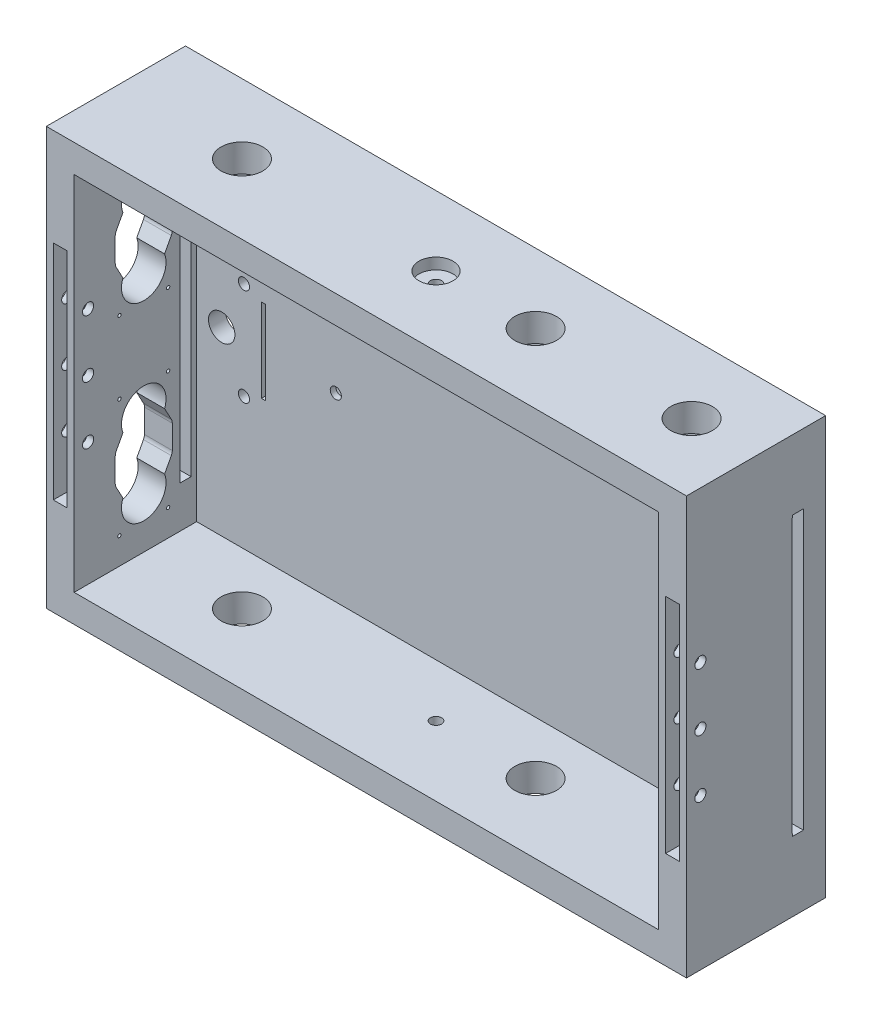
from build123d import *

# Parameters (mm, degrees)
SKETCH1_W           = 230
SKETCH1_H           = 50
BOSS_EXTRUDE1_DEPTH = 150
SKETCH2_W           = 210
SKETCH2_H           = 130
CUT_EXTRUDE1_DEPTH  = 44
SKETCH3_R           = 6.125
CUT_EXTRUDE2_DEPTH  = 4
SKETCH4_R           = 6.125
CUT_EXTRUDE4_DEPTH  = 4
SKETCH5_R           = 6.125
CUT_EXTRUDE5_DEPTH  = 4
SKETCH7_R           = 2
CUT_EXTRUDE7_DEPTH  = 47
SKETCH8_R           = 2
CUT_EXTRUDE8_DEPTH  = 147
CUT_EXTRUDE9_REACH  = 52
SKETCH10_R          = 2
SKETCH10_R_2        = 4.75
SKETCH10_W          = 1.5
SKETCH10_H          = 30
SKETCH11_R          = 7.5
CUT_EXTRUDE10_DEPTH = 151
CUT_EXTRUDE12_REACH = 232
SKETCH14_R          = 0.6
SKETCH15_W          = 5
SKETCH15_H          = 80
CUT_EXTRUDE13_DEPTH = 10
SKETCH16_R          = 2
CUT_EXTRUDE14_DEPTH = 231
CUT_EXTRUDE15_DEPTH = 231


with BuildPart() as part:
    # Sketch1 → Boss-Extrude1 (new body)
    with BuildSketch(Plane(origin=(0, 0, 0), x_dir=(1, 0, 0), z_dir=(0, 1, 0))):
        with Locations((115, 25)):
            Rectangle(SKETCH1_W, SKETCH1_H)
    extrude(amount=BOSS_EXTRUDE1_DEPTH)

    # Sketch2 → Cut-Extrude1 (cut)
    with BuildSketch(Plane.XY):
        with Locations((115, 75)):
            Rectangle(SKETCH2_W, SKETCH2_H)
    extrude(amount=-CUT_EXTRUDE1_DEPTH, mode=Mode.SUBTRACT)

    # Sketch3 → Cut-Extrude2 (cut)
    with BuildSketch(Plane(origin=(0, 150, 0), x_dir=(1, 0, 0), z_dir=(0, 1, 0))):
        with Locations((115, 25)):
            Circle(SKETCH3_R)
    extrude(amount=-CUT_EXTRUDE2_DEPTH, mode=Mode.SUBTRACT)

    # Sketch4 → Cut-Extrude4 (cut)
    with BuildSketch(Plane(origin=(0, 0, 0), x_dir=(1, 0, 0), z_dir=(0, 1, 0))):
        with Locations((115, 25)):
            Circle(SKETCH4_R)
    extrude(amount=CUT_EXTRUDE4_DEPTH, mode=Mode.SUBTRACT)

    # Sketch5 → Cut-Extrude5 (cut)
    with BuildSketch(Plane(origin=(0, 0, -50), x_dir=(-1, 0, 0), z_dir=(0, 0, -1))):
        with Locations((-60, 75)):
            Circle(SKETCH5_R)
    extrude(amount=-CUT_EXTRUDE5_DEPTH, mode=Mode.SUBTRACT)

    # Sketch7 → Cut-Extrude7 (cut, through all)
    with BuildSketch(Plane(origin=(0, 0, -46), x_dir=(-1, 0, 0), z_dir=(0, 0, -1))):
        with Locations((-60, 75)):
            Circle(SKETCH7_R)
    extrude(amount=-CUT_EXTRUDE7_DEPTH, mode=Mode.SUBTRACT)

    # Sketch8 → Cut-Extrude8 (cut, through all)
    with BuildSketch(Plane(origin=(0, 146, 0), x_dir=(1, 0, 0), z_dir=(0, 1, 0))):
        with Locations((115, 25)):
            Circle(SKETCH8_R)
    extrude(amount=-CUT_EXTRUDE8_DEPTH, mode=Mode.SUBTRACT)

    # Sketch10 → Cut-Extrude9 (cut, up to next)
    with BuildSketch(Plane(origin=(0, 0, -50), x_dir=(-1, 0, 0), z_dir=(0, 0, -1)), mode=Mode.PRIVATE) as cut_extrude9_sk1:
        with Locations((-27, 92.5)):
            Circle(SKETCH10_R)
    cut_extrude9_tool1 = extrude(cut_extrude9_sk1.sketch, amount=-CUT_EXTRUDE9_REACH, mode=Mode.PRIVATE) & part.part
    add(cut_extrude9_tool1.solids().sort_by_distance((27, 92.5, -50))[0], mode=Mode.SUBTRACT)
    # Sketch10 → Cut-Extrude9 (cut, up to next)
    with BuildSketch(Plane(origin=(0, 0, -50), x_dir=(-1, 0, 0), z_dir=(0, 0, -1)), mode=Mode.PRIVATE) as cut_extrude9_sk2:
        with Locations((-27, 57.5)):
            Circle(SKETCH10_R)
    cut_extrude9_tool2 = extrude(cut_extrude9_sk2.sketch, amount=-CUT_EXTRUDE9_REACH, mode=Mode.PRIVATE) & part.part
    add(cut_extrude9_tool2.solids().sort_by_distance((27, 57.5, -50))[0], mode=Mode.SUBTRACT)
    # Sketch10 → Cut-Extrude9 (cut, up to next)
    with BuildSketch(Plane(origin=(0, 0, -50), x_dir=(-1, 0, 0), z_dir=(0, 0, -1)), mode=Mode.PRIVATE) as cut_extrude9_sk3:
        with Locations((-19, 75)):
            Circle(SKETCH10_R_2)
    cut_extrude9_tool3 = extrude(cut_extrude9_sk3.sketch, amount=-CUT_EXTRUDE9_REACH, mode=Mode.PRIVATE) & part.part
    add(cut_extrude9_tool3.solids().sort_by_distance((19, 75, -50))[0], mode=Mode.SUBTRACT)
    # Sketch10 → Cut-Extrude9 (cut, up to next)
    with BuildSketch(Plane(origin=(0, 0, -50), x_dir=(-1, 0, 0), z_dir=(0, 0, -1)), mode=Mode.PRIVATE) as cut_extrude9_sk4:
        with Locations((-34.018423534, 75)):
            Rectangle(SKETCH10_W, SKETCH10_H)
    cut_extrude9_tool4 = extrude(cut_extrude9_sk4.sketch, amount=-CUT_EXTRUDE9_REACH, mode=Mode.PRIVATE) & part.part
    add(cut_extrude9_tool4.solids().sort_by_distance((34.018424, 75, -50))[0], mode=Mode.SUBTRACT)

    # Sketch11 → Cut-Extrude10 (cut, through all)
    with BuildSketch(Plane(origin=(0, 150, 0), x_dir=(1, 0, 0), z_dir=(0, 1, 0))):
        with Locations((45.280155496, 25)):
            Circle(SKETCH11_R)
        with Locations((150.781597071, 25)):
            Circle(SKETCH11_R)
        with Locations((206.820659907, 25)):
            Circle(SKETCH11_R)
    extrude(amount=-CUT_EXTRUDE10_DEPTH, mode=Mode.SUBTRACT)

    # Sketch14 → Cut-Extrude12 (cut, up to next)
    with BuildSketch(Plane.ZY, mode=Mode.PRIVATE) as cut_extrude12_sk1:
        with Locations((-33.75, 62)):
            Circle(SKETCH14_R)
    cut_extrude12_tool1 = extrude(cut_extrude12_sk1.sketch, amount=-CUT_EXTRUDE12_REACH, mode=Mode.PRIVATE) & part.part
    add(cut_extrude12_tool1.solids().sort_by_distance((0, 62, -33.75))[0], mode=Mode.SUBTRACT)
    # Sketch14 → Cut-Extrude12 (cut, up to next)
    with BuildSketch(Plane.ZY, mode=Mode.PRIVATE) as cut_extrude12_sk2:
        with Locations((-16.25, 19.5)):
            Circle(SKETCH14_R)
    cut_extrude12_tool2 = extrude(cut_extrude12_sk2.sketch, amount=-CUT_EXTRUDE12_REACH, mode=Mode.PRIVATE) & part.part
    add(cut_extrude12_tool2.solids().sort_by_distance((0, 19.5, -16.25))[0], mode=Mode.SUBTRACT)
    # Sketch14 → Cut-Extrude12 (cut, up to next)
    with BuildSketch(Plane.ZY, mode=Mode.PRIVATE) as cut_extrude12_sk3:
        with Locations((-16.25, 62)):
            Circle(SKETCH14_R)
    cut_extrude12_tool3 = extrude(cut_extrude12_sk3.sketch, amount=-CUT_EXTRUDE12_REACH, mode=Mode.PRIVATE) & part.part
    add(cut_extrude12_tool3.solids().sort_by_distance((0, 62, -16.25))[0], mode=Mode.SUBTRACT)
    # Sketch14 → Cut-Extrude12 (cut, up to next)
    with BuildSketch(Plane.ZY, mode=Mode.PRIVATE) as cut_extrude12_sk4:
        with Locations((-33.75, 19.5)):
            Circle(SKETCH14_R)
    cut_extrude12_tool4 = extrude(cut_extrude12_sk4.sketch, amount=-CUT_EXTRUDE12_REACH, mode=Mode.PRIVATE) & part.part
    add(cut_extrude12_tool4.solids().sort_by_distance((0, 19.5, -33.75))[0], mode=Mode.SUBTRACT)
    # Sketch14 → Cut-Extrude12 (cut, up to next)
    with BuildSketch(Plane.ZY, mode=Mode.PRIVATE) as cut_extrude12_sk5:
        with Locations((-33.75, 130.5)):
            Circle(SKETCH14_R)
    cut_extrude12_tool5 = extrude(cut_extrude12_sk5.sketch, amount=-CUT_EXTRUDE12_REACH, mode=Mode.PRIVATE) & part.part
    add(cut_extrude12_tool5.solids().sort_by_distance((0, 130.5, -33.75))[0], mode=Mode.SUBTRACT)
    # Sketch14 → Cut-Extrude12 (cut, up to next)
    with BuildSketch(Plane.ZY, mode=Mode.PRIVATE) as cut_extrude12_sk6:
        with Locations((-16.25, 88)):
            Circle(SKETCH14_R)
    cut_extrude12_tool6 = extrude(cut_extrude12_sk6.sketch, amount=-CUT_EXTRUDE12_REACH, mode=Mode.PRIVATE) & part.part
    add(cut_extrude12_tool6.solids().sort_by_distance((0, 88, -16.25))[0], mode=Mode.SUBTRACT)
    # Sketch14 → Cut-Extrude12 (cut, up to next)
    with BuildSketch(Plane.ZY, mode=Mode.PRIVATE) as cut_extrude12_sk7:
        with Locations((-16.25, 130.5)):
            Circle(SKETCH14_R)
    cut_extrude12_tool7 = extrude(cut_extrude12_sk7.sketch, amount=-CUT_EXTRUDE12_REACH, mode=Mode.PRIVATE) & part.part
    add(cut_extrude12_tool7.solids().sort_by_distance((0, 130.5, -16.25))[0], mode=Mode.SUBTRACT)
    # Sketch14 → Cut-Extrude12 (cut, up to next)
    with BuildSketch(Plane.ZY, mode=Mode.PRIVATE) as cut_extrude12_sk8:
        with Locations((-33.75, 88)):
            Circle(SKETCH14_R)
    cut_extrude12_tool8 = extrude(cut_extrude12_sk8.sketch, amount=-CUT_EXTRUDE12_REACH, mode=Mode.PRIVATE) & part.part
    add(cut_extrude12_tool8.solids().sort_by_distance((0, 88, -33.75))[0], mode=Mode.SUBTRACT)
    # Sketch14 → Cut-Extrude12 (cut, up to next)
    with BuildSketch(Plane.ZY, mode=Mode.PRIVATE) as cut_extrude12_sk9:
        with BuildLine():
            Line((-35.25, 44.99795855), (-35.25, 36.50204145))
            ThreePointArc((-35.25, 36.50204145), (-35.159960979, 35.772571025), (-34.895248599, 35.086887802))
            Line((-34.895248599, 35.086887802), (-32.483314774, 30.578427125))
            ThreePointArc((-32.483314774, 30.578427125), (-25, 19.75), (-17.516685226, 30.578427125))
            Line((-17.516685226, 30.578427125), (-15.104751401, 35.086887802))
            ThreePointArc((-15.104751401, 35.086887802), (-14.840039021, 35.772571025), (-14.75, 36.50204145))
            Line((-14.75, 36.50204145), (-14.75, 44.99795855))
            ThreePointArc((-14.75, 44.99795855), (-14.840039021, 45.727428975), (-15.104751401, 46.413112198))
            Line((-15.104751401, 46.413112198), (-17.516685226, 50.921572875))
            ThreePointArc((-17.516685226, 50.921572875), (-25, 61.75), (-32.483314774, 50.921572875))
            Line((-32.483314774, 50.921572875), (-34.895248599, 46.413112198))
            ThreePointArc((-34.895248599, 46.413112198), (-35.159960979, 45.727428975), (-35.25, 44.99795855))
        make_face()
    cut_extrude12_tool9 = extrude(cut_extrude12_sk9.sketch, amount=-CUT_EXTRUDE12_REACH, mode=Mode.PRIVATE) & part.part
    add(cut_extrude12_tool9.solids().sort_by_distance((0, 40.75, -25))[0], mode=Mode.SUBTRACT)
    # Sketch14 → Cut-Extrude12 (cut, up to next)
    with BuildSketch(Plane.ZY, mode=Mode.PRIVATE) as cut_extrude12_sk10:
        with BuildLine():
            Line((-34.895248599, 103.586887802), (-32.483314774, 99.078427125))
            ThreePointArc((-32.483314774, 99.078427125), (-25, 88.25), (-17.516685226, 99.078427125))
            Line((-17.516685226, 99.078427125), (-15.104751401, 103.586887802))
            ThreePointArc((-15.104751401, 103.586887802), (-14.840039021, 104.272571025), (-14.75, 105.00204145))
            Line((-14.75, 105.00204145), (-14.75, 113.49795855))
            ThreePointArc((-14.75, 113.49795855), (-14.840039021, 114.227428975), (-15.104751401, 114.913112198))
            Line((-15.104751401, 114.913112198), (-17.516685226, 119.421572875))
            ThreePointArc((-17.516685226, 119.421572875), (-25, 130.25), (-32.483314774, 119.421572875))
            Line((-32.483314774, 119.421572875), (-34.895248599, 114.913112198))
            ThreePointArc((-34.895248599, 114.913112198), (-35.159960979, 114.227428975), (-35.25, 113.49795855))
            Line((-35.25, 113.49795855), (-35.25, 105.00204145))
            ThreePointArc((-35.25, 105.00204145), (-35.159960979, 104.272571025), (-34.895248599, 103.586887802))
        make_face()
    cut_extrude12_tool10 = extrude(cut_extrude12_sk10.sketch, amount=-CUT_EXTRUDE12_REACH, mode=Mode.PRIVATE) & part.part
    add(cut_extrude12_tool10.solids().sort_by_distance((0, 109.25, -25))[0], mode=Mode.SUBTRACT)

    # Sketch15 → Cut-Extrude13 (cut)
    with BuildSketch(Plane.XY):
        with Locations((5, 75)):
            Rectangle(SKETCH15_W, SKETCH15_H)
    cut_extrude13 = extrude(amount=-CUT_EXTRUDE13_DEPTH, mode=Mode.SUBTRACT)

    # Sketch16 → Cut-Extrude14 (cut, through all)
    with BuildSketch(Plane.ZY):
        with Locations((-5, 54.275849875)):
            Circle(SKETCH16_R)
        with Locations((-5, 75)):
            Circle(SKETCH16_R)
        with Locations((-5, 95.724150125)):
            Circle(SKETCH16_R)
    extrude(amount=-CUT_EXTRUDE14_DEPTH, mode=Mode.SUBTRACT)

    # Sketch17 → Cut-Extrude15 (cut, through all)
    with BuildSketch(Plane.ZY):
        Polygon((-38, 25), (-37.940213387, 75), (-38, 125), (-42, 125), (-42, 25), align=None)
    extrude(amount=-CUT_EXTRUDE15_DEPTH, mode=Mode.SUBTRACT)

    # Mirror1: Cut-Extrude13 across plane
    add(cut_extrude13.mirror(Plane(origin=(115, 0, 0), x_dir=(0, 0, 1), z_dir=(1, 0, 0))), mode=Mode.SUBTRACT)


solid = part.part
